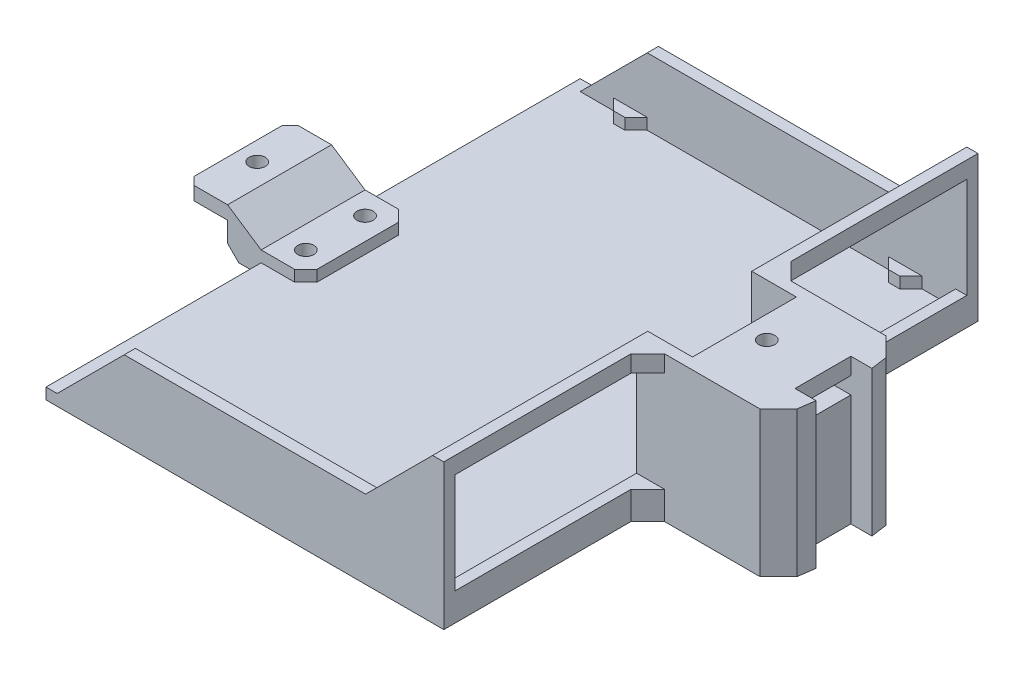
from build123d import *

# Parameters (mm, degrees)
SKETCH3_W                                       = 90.422573022
SKETCH3_H                                       = 121.412
BOSS_EXTRUDE4_DEPTH                             = 2.54
BOSS_EXTRUDE5_DEPTH                             = 30.48
CUT_EXTRUDE2_DEPTH                              = 122.412
BOSS_EXTRUDE6_DEPTH                             = 33.02
SKETCH9_W                                       = 10.16
SKETCH9_H                                       = 23.622
CUT_EXTRUDE3_DEPTH                              = 27.94
BOSS_EXTRUDE7_DEPTH                             = 2.54
SKETCH12_W                                      = 23.622
SKETCH12_H                                      = 3.81
CUT_EXTRUDE4_DEPTH                              = 10.16
SKETCH13_W                                      = 12.7
SKETCH13_H                                      = 3.81
CUT_EXTRUDE5_DEPTH                              = 13.461069207
BOSS_EXTRUDE9_REACH                             = 62.706
BOSS_EXTRUDE9_DIRECTION_2_REACH                 = 62.706
CBORE_FOR_6_PAN_HEAD_MACHINE_SCREW1_D           = 3.6576
CBORE_FOR_6_PAN_HEAD_MACHINE_SCREW1_CBORE_D     = 7.54126
CBORE_FOR_6_PAN_HEAD_MACHINE_SCREW1_CBORE_DEPTH = 2.4638
F_6_CLEARANCE_HOLE1_D                           = 3.6576
SKETCH21_W                                      = 43.815
SKETCH21_H                                      = 22.86
CUT_EXTRUDE6_DEPTH                              = 33.781069207
CHAMFER1_SIZE                                   = 2.54
CHAMFER2_SIZE                                   = 3.81
SKETCH23_W                                      = 10.16
SKETCH23_H                                      = 23.622
CUT_EXTRUDE8_DEPTH                              = 0.762
CHAMFER3_SIZE                                   = 0.762


with BuildPart() as part:
    # Sketch3 → Boss-Extrude4 (new body)
    with BuildSketch(Plane(origin=(0, 0, 0), x_dir=(1, 0, 0), z_dir=(0, 1, 0))):
        Rectangle(SKETCH3_W, SKETCH3_H)
    extrude(amount=BOSS_EXTRUDE4_DEPTH)

    # Sketch6 → Boss-Extrude5 (add)
    with BuildSketch(Plane(origin=(0, 2.54, 0), x_dir=(1, 0, 0), z_dir=(0, 1, 0))):
        Polygon((45.211286511, -60.706), (45.211286511, 60.706), (-45.211286511, 60.706), (-45.211286511, 58.166), (42.671286511, 58.166), (42.671286511, -58.166), (-45.211286511, -58.166), (-45.211286511, -60.706), align=None)
    extrude(amount=BOSS_EXTRUDE5_DEPTH)

    # Sketch7 → Cut-Extrude2 (cut, through all)
    with BuildSketch(Plane.XY.offset(60.706)):
        Polygon((-42.671286511, 2.54), (-27.431286511, 17.78), (27.431286511, 17.78), (42.671286511, 33.02), (-45.211286511, 33.02), (-45.211286511, 2.54), align=None)
    extrude(amount=-CUT_EXTRUDE2_DEPTH, mode=Mode.SUBTRACT)

    # Sketch8 → Boss-Extrude6 (add)
    with BuildSketch(Plane(origin=(0, 0, 0), x_dir=(1, 0, 0), z_dir=(0, 1, 0))):
        Polygon((45.211286511, 14.351), (70.694027546, 14.351), (74.922106204, 10.122921342), (75.452355719, 6.35), (70.677155719, 6.35), (70.677155719, -6.35), (75.452355719, -6.35), (74.922106204, -10.122921342), (70.694027546, -14.351), (45.211286511, -14.351), align=None)
    extrude(amount=BOSS_EXTRUDE6_DEPTH)

    # Sketch9 → Cut-Extrude3 (cut)
    with BuildSketch(Plane(origin=(0, 33.02, 0), x_dir=(1, 0, 0), z_dir=(0, 1, 0))):
        with Locations((47.751286511, 0)):
            Rectangle(SKETCH9_W, SKETCH9_H)
    extrude(amount=-CUT_EXTRUDE3_DEPTH, mode=Mode.SUBTRACT)

    # Sketch11 → Boss-Extrude7 (add)
    with BuildSketch(Plane(origin=(0, 2.54, 0), x_dir=(1, 0, 0), z_dir=(0, 1, 0))):
        Polygon((35.051286511, 58.166), (27.431286511, 58.166), (29.971286511, 55.626), (32.511286511, 55.626), align=None)
        Polygon((-29.971286511, 55.626), (-32.511286511, 55.626), (-35.051286511, 58.166), (-27.431286511, 58.166), align=None)
        Polygon((29.971286511, -55.626), (32.511286511, -55.626), (35.051286511, -58.166), (27.431286511, -58.166), align=None)
        Polygon((-27.431286511, -58.166), (-29.971286511, -55.626), (-32.511286511, -55.626), (-35.051286511, -58.166), align=None)
    extrude(amount=BOSS_EXTRUDE7_DEPTH)

    # Sketch12 → Cut-Extrude4 (cut)
    with BuildSketch(Plane.ZY.offset(-52.831286511)):
        with Locations((0, 27.305)):
            Rectangle(SKETCH12_W, SKETCH12_H)
    extrude(amount=-CUT_EXTRUDE4_DEPTH, mode=Mode.SUBTRACT)

    # Sketch13 → Cut-Extrude5 (cut, through all)
    with BuildSketch(Plane.ZY.offset(-62.991286511)):
        with Locations((0, 27.305)):
            Rectangle(SKETCH13_W, SKETCH13_H)
    extrude(amount=-CUT_EXTRUDE5_DEPTH, mode=Mode.SUBTRACT)

    # Boss-Extrude9: up to this face of the body (flat: up to its plane)
    boss_extrude9_end = Plane(part.part.faces().sort_by_distance((48.970486511, 20.0406, -11.811))[0])
    # Sketch15 → Boss-Extrude9 (add, up to the picked face)
    with BuildSketch(Plane.XY, mode=Mode.PRIVATE) as boss_extrude9_sk1:
        Polygon((-62.991286511, 10.16), (-52.831286511, 10.16), (-45.211286511, 5.08), (-35.051286511, 5.08), (-35.051286511, 2.54), (-45.211286511, 2.54), (-45.211286511, 0), (-52.831286511, 0), (-52.831286511, 6.35), (-62.991286511, 6.35), align=None)
    boss_extrude9_tool1 = split(extrude(boss_extrude9_sk1.sketch, amount=-BOSS_EXTRUDE9_REACH, mode=Mode.PRIVATE), bisect_by=boss_extrude9_end, keep=Keep.BOTH, mode=Mode.PRIVATE)
    add(boss_extrude9_tool1.solids().sort_by_distance((-50.157602, 5.280526, 0))[0])

    # Boss-Extrude9 direction 2: up to this face of the body (flat: up to its plane)
    boss_extrude9_direction_2_end = Plane(part.part.faces().sort_by_distance((48.970486511, 20.0406, 11.811))[0])
    # Sketch15 → Boss-Extrude9 direction 2 (add, up to the picked face)
    with BuildSketch(Plane.XY, mode=Mode.PRIVATE) as boss_extrude9_direction_2_sk1:
        Polygon((-62.991286511, 10.16), (-52.831286511, 10.16), (-45.211286511, 5.08), (-35.051286511, 5.08), (-35.051286511, 2.54), (-45.211286511, 2.54), (-45.211286511, 0), (-52.831286511, 0), (-52.831286511, 6.35), (-62.991286511, 6.35), align=None)
    boss_extrude9_direction_2_tool1 = split(extrude(boss_extrude9_direction_2_sk1.sketch, amount=BOSS_EXTRUDE9_DIRECTION_2_REACH, mode=Mode.PRIVATE), bisect_by=boss_extrude9_direction_2_end, keep=Keep.BOTH, mode=Mode.PRIVATE)
    add(boss_extrude9_direction_2_tool1.solids().sort_by_distance((-50.157602, 5.280526, 0))[0])

    # CBORE for #6 Pan Head Machine Screw1 (through all)
    with Locations(Plane(origin=(0, 0, 0), x_dir=(-1, 0, 0), z_dir=(0, -1, 0))):
        with Locations((-47.751286511, 6.731), (-47.751286511, -6.731), (40.131286511, 6.731), (40.131286511, -6.731)):
            CounterBoreHole(CBORE_FOR_6_PAN_HEAD_MACHINE_SCREW1_D / 2, CBORE_FOR_6_PAN_HEAD_MACHINE_SCREW1_CBORE_D / 2, CBORE_FOR_6_PAN_HEAD_MACHINE_SCREW1_CBORE_DEPTH)

    # #6 Clearance Hole1 (through all)
    with Locations(Plane(origin=(0, 33.02, 0), x_dir=(1, 0, 0), z_dir=(0, 1, 0))):
        with Locations((-57.911286511, 0), (57.911286511, 0)):
            Hole(F_6_CLEARANCE_HOLE1_D / 2)

    # Sketch21 → Cut-Extrude6 (cut, through all)
    with BuildSketch(Plane.ZY.offset(-42.671286511)):
        with Locations((-36.2585, 17.78)):
            Rectangle(SKETCH21_W, SKETCH21_H)
        with Locations((36.2585, 17.78)):
            Rectangle(SKETCH21_W, SKETCH21_H)
    extrude(amount=-CUT_EXTRUDE6_DEPTH, mode=Mode.SUBTRACT)

    # Chamfer1
    chamfer1_edges = [part.edges().sort_by_distance(p)[0] for p in [
        (-52.831286511, 0, 0),
        (-35.051286511, 3.81, -11.811),
        (-62.991286511, 8.255, -11.811),
        (-62.991286511, 8.255, 11.811),
        (-35.051286511, 3.81, 11.811),
    ]]
    chamfer(chamfer1_edges, length=CHAMFER1_SIZE)

    # Chamfer2
    chamfer2_edges = [part.edges().sort_by_distance(p)[0] for p in [
        (45.211286511, 3.175, -14.351),
        (45.211286511, 3.175, 14.351),
        (45.211286511, 31.115, -14.351),
        (45.211286511, 31.115, 14.351),
    ]]
    chamfer(chamfer2_edges, length=CHAMFER2_SIZE)

    # Sketch23 → Cut-Extrude8 (cut)
    with BuildSketch(Plane.XZ.offset(-6.35)):
        with Locations((-57.911286511, 0)):
            Rectangle(SKETCH23_W, SKETCH23_H)
    extrude(amount=-CUT_EXTRUDE8_DEPTH, mode=Mode.SUBTRACT)

    # Chamfer3
    chamfer3_edges = [part.edges().sort_by_distance(p)[0] for p in [
        (-62.991286511, 10.16, 0),
        (-62.991286511, 7.112, 0),
    ]]
    chamfer(chamfer3_edges, length=CHAMFER3_SIZE)


solid = part.part
